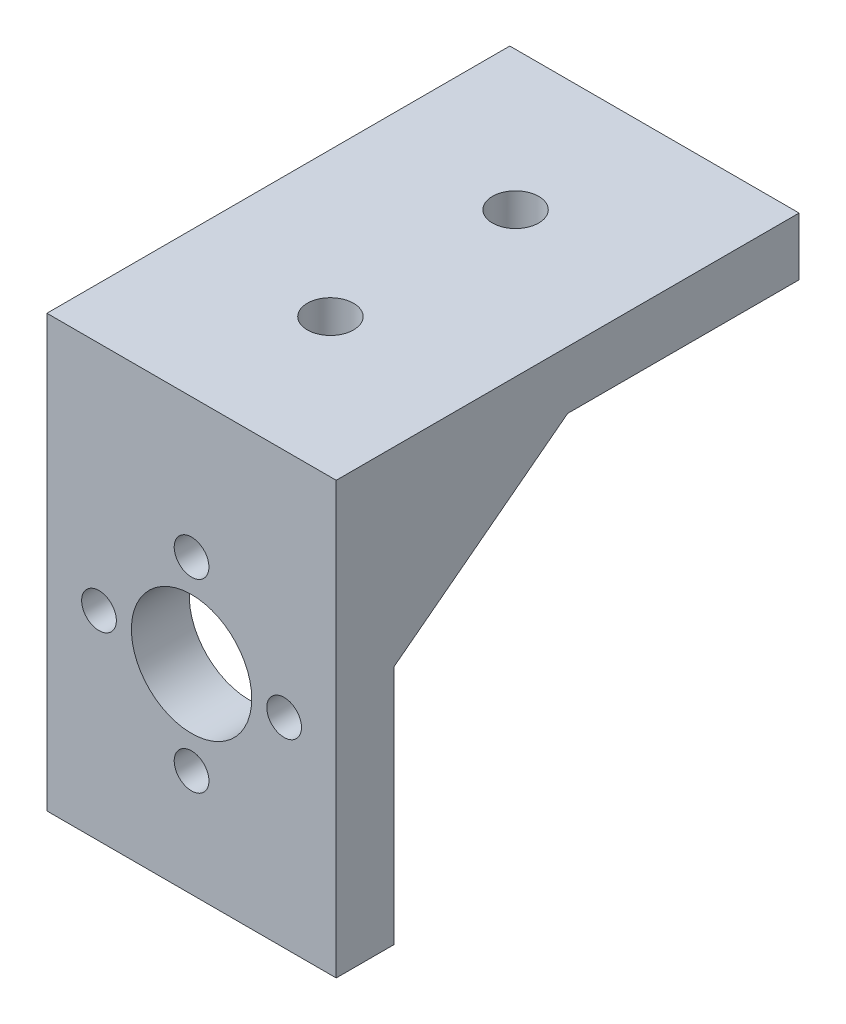
from build123d import *

# Parameters (mm, degrees)
SKETCH1_W           = 25
SKETCH1_H           = 40
BOSS_EXTRUDE1_DEPTH = 5
SKETCH2_R           = 2
CUT_EXTRUDE1_DEPTH  = 11.5
SKETCH3_W           = 25
SKETCH3_H           = 5
BOSS_EXTRUDE2_DEPTH = 32.25
SKETCH5_R           = 11.1
CUT_EXTRUDE2_DEPTH  = 1.5
SKETCH6_R           = 5.2
CUT_EXTRUDE3_DEPTH  = 10.5
SKETCH7_R           = 1.5
CUT_EXTRUDE4_DEPTH  = 10.5
CIRPATTERN1_COUNT   = 4
BOSS_EXTRUDE3_DEPTH = 3
BOSS_EXTRUDE4_START = 1.5
SKETCH9_R           = 11.1
SKETCH9_R_2         = 5.2
SKETCH9_R_3         = 1.5
BOSS_EXTRUDE4_DEPTH = 1.5


with BuildPart() as part:
    # Sketch1 → Boss-Extrude1 (new body)
    with BuildSketch(Plane(origin=(0, 0, 0), x_dir=(1, 0, 0), z_dir=(0, 1, 0))):
        Rectangle(SKETCH1_W, SKETCH1_H)
    extrude(amount=BOSS_EXTRUDE1_DEPTH)

    # Sketch2 → Cut-Extrude1 (cut)
    with BuildSketch(Plane(origin=(0, 5, 0), x_dir=(1, 0, 0), z_dir=(0, 1, 0))):
        with Locations(Location((0, 8, 0), (0, 0, 270))):
            Circle(SKETCH2_R)
    cut_extrude1 = extrude(amount=-CUT_EXTRUDE1_DEPTH, mode=Mode.SUBTRACT)

    # Mirror1: Cut-Extrude1 across plane
    add(cut_extrude1.mirror(Plane.XY), mode=Mode.SUBTRACT)

    # Sketch3 → Boss-Extrude2 (add)
    with BuildSketch(Plane.XZ):
        with Locations((0, 17.5)):
            Rectangle(SKETCH3_W, SKETCH3_H)
    extrude(amount=BOSS_EXTRUDE2_DEPTH)

    # Sketch5 → Cut-Extrude2 (cut)
    with BuildSketch(Plane.XY.offset(20)):
        with Locations((0, -15)):
            Circle(SKETCH5_R)
    extrude(amount=-CUT_EXTRUDE2_DEPTH, mode=Mode.SUBTRACT)

    # Sketch6 → Cut-Extrude3 (cut)
    with BuildSketch(Plane.XY.offset(18.5)):
        with Locations((0, -15)):
            Circle(SKETCH6_R)
    extrude(amount=-CUT_EXTRUDE3_DEPTH, mode=Mode.SUBTRACT)

    # Sketch7 → Cut-Extrude4 (cut)
    with BuildSketch(Plane.XY.offset(18.5)):
        with Locations((0, -7)):
            Circle(SKETCH7_R)
    cut_extrude4 = extrude(amount=-CUT_EXTRUDE4_DEPTH, mode=Mode.SUBTRACT)

    # CirPattern1: Cut-Extrude4 ×4 about axis
    cirpattern1_axis = Axis((0, -15, 0), (0, 0, 1))
    for i in range(1, CIRPATTERN1_COUNT):
        add(cut_extrude4.rotate(cirpattern1_axis, i * 360 / CIRPATTERN1_COUNT), mode=Mode.SUBTRACT)

    # Sketch8 → Boss-Extrude3 (add)
    with BuildSketch(Plane.ZY.offset(12.5)):
        Polygon((15, 0), (0, 0), (15, -11.4463543), align=None)
    boss_extrude3 = extrude(amount=-BOSS_EXTRUDE3_DEPTH)

    # Mirror2: Boss-Extrude3 across plane
    add(boss_extrude3.mirror(Plane(origin=(0, 0, 0), x_dir=(0, 0, 1), z_dir=(1, 0, 0))))

    # Sketch9 → Boss-Extrude4 (add)
    with BuildSketch(Plane.XY.offset(18.5).offset(BOSS_EXTRUDE4_START)):
        with Locations((0, -15)):
            Circle(SKETCH9_R)
        with Locations((0, -15)):
            Circle(SKETCH9_R_2, mode=Mode.SUBTRACT)
        with Locations((0, -7)):
            Circle(SKETCH9_R_3, mode=Mode.SUBTRACT)
        with Locations((-8, -15)):
            Circle(SKETCH9_R_3, mode=Mode.SUBTRACT)
        with Locations((8, -15)):
            Circle(SKETCH9_R_3, mode=Mode.SUBTRACT)
        with Locations((0, -23)):
            Circle(SKETCH9_R_3, mode=Mode.SUBTRACT)
    extrude(amount=-BOSS_EXTRUDE4_DEPTH)


solid = part.part
